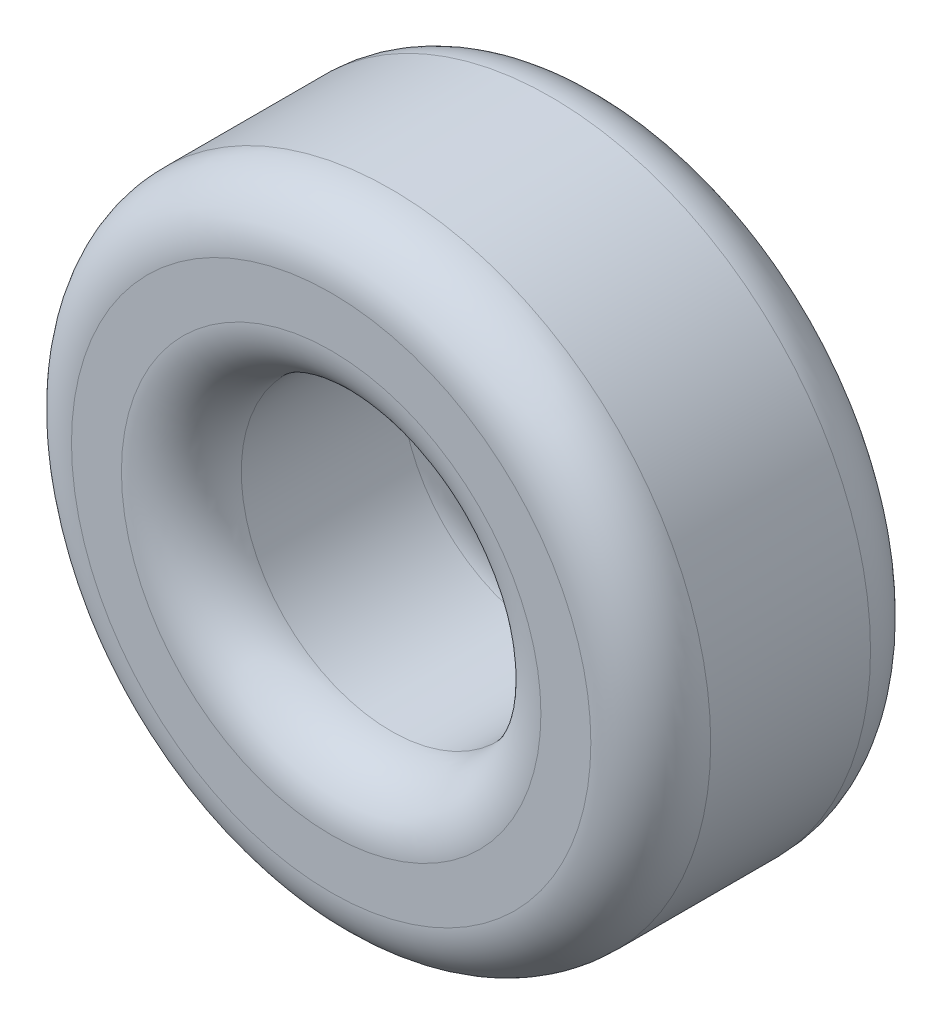
from build123d import *

# Parameters (mm, degrees)
SKETCH1_R           = 1.6
SKETCH1_R_2         = 0.75
BOSS_EXTRUDE1_DEPTH = 0.7
FILLET2_R           = 0.3


with BuildPart() as part:
    # Sketch1 → Boss-Extrude1 (new body, symmetric)
    with BuildSketch(Plane.XY):
        Circle(SKETCH1_R)
        Circle(SKETCH1_R_2, mode=Mode.SUBTRACT)
    extrude(amount=BOSS_EXTRUDE1_DEPTH, both=True)

    # Fillet2
    fillet2_edges = [part.edges().sort_by_distance(p)[0] for p in [
        (-1.6, 0, -0.7),
        (-1.6, 0, 0.7),
        (-0.75, 0, -0.7),
        (-0.75, 0, 0.7),
    ]]
    fillet(fillet2_edges, radius=FILLET2_R)


solid = part.part
